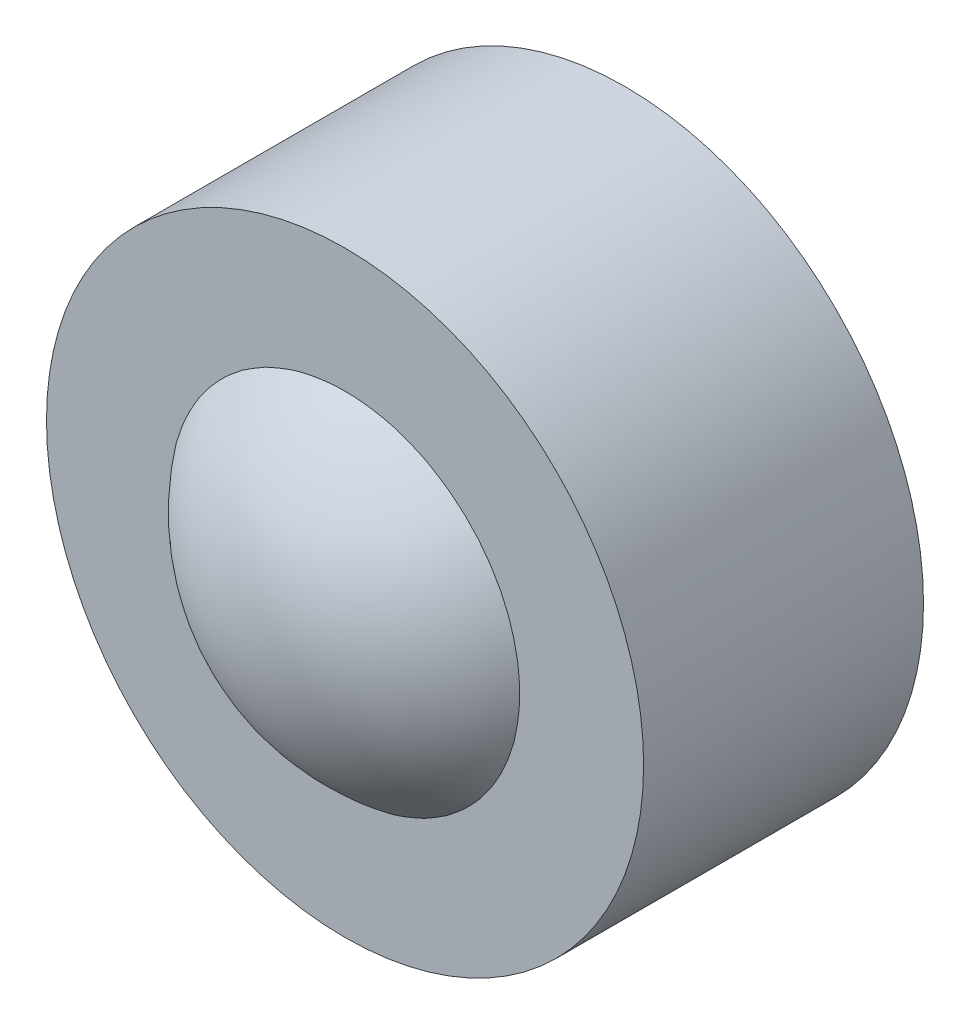
from build123d import *

# Parameters (mm, degrees)
SKETCH1_R           = 4
SKETCH1_R_2         = 2
BOSS_EXTRUDE1_DEPTH = 1.875


with BuildPart() as part:
    # Sketch1 → Boss-Extrude1 (new body, symmetric)
    with BuildSketch(Plane.XY):
        Circle(SKETCH1_R)
        Circle(SKETCH1_R_2, mode=Mode.SUBTRACT)
    extrude(amount=BOSS_EXTRUDE1_DEPTH, both=True)


with BuildPart() as body_2:
    # Sketch2 → Revolve1 (revolve)
    with BuildSketch(Plane.XY):
        with BuildLine():
            Line((0, -3), (0, 3))
            ThreePointArc((0, 3), (-3, 0), (0, -3))
        make_face()
    revolve(axis=Axis((0, -3, 0), (0, 1, 0)))


solid = Compound([part.part, body_2.part])
